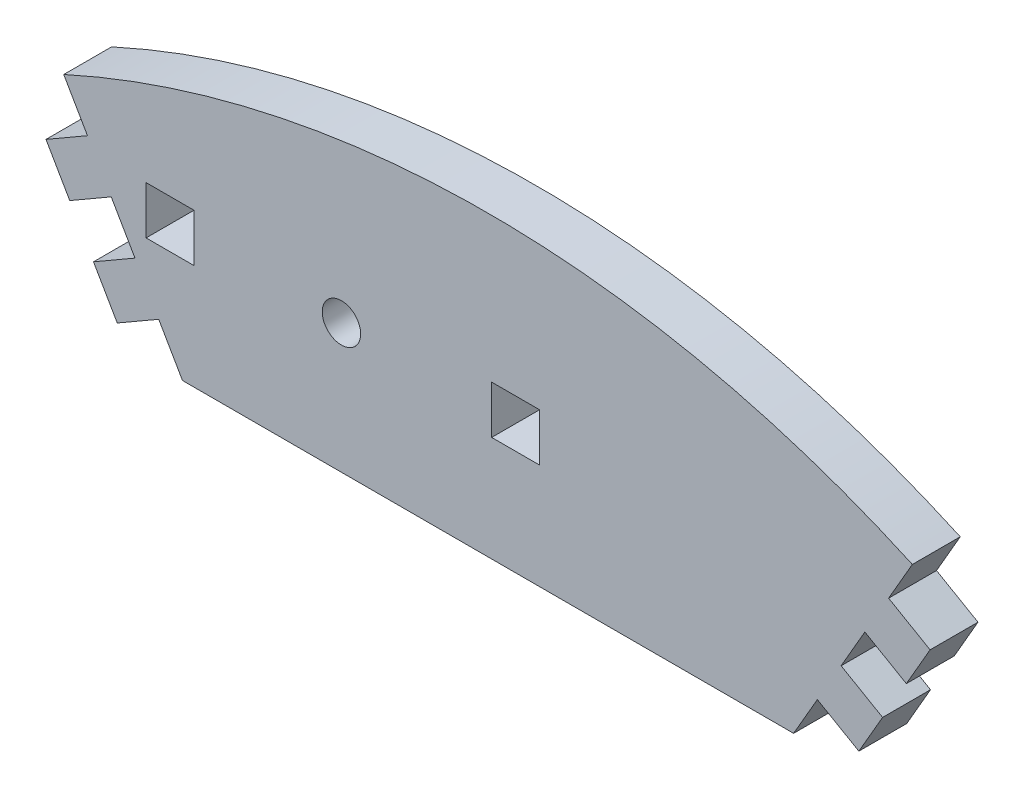
from build123d import *

# Parameters (mm, degrees)
BOSS_EXTRUDE1_DEPTH = 5.15
SKETCH2_R           = 2.0675
SKETCH2_W           = 5.15
SKETCH2_H           = 5.15
CUT_EXTRUDE1_DEPTH  = 6.15


with BuildPart() as part:
    # Sketch1 → Boss-Extrude1 (new body)
    with BuildSketch(Plane.XY):
        with BuildLine():
            Line((-32.85, 77.986683936), (32.85, 77.986683936))
            Line((32.85, 77.986683936), (35.403, 82.408609648))
            Line((35.403, 82.408609648), (39.863030829, 79.833609648))
            Line((39.863030829, 79.833609648), (42.416030829, 84.255535359))
            Line((42.416030829, 84.255535359), (37.956, 86.830535359))
            Line((37.956, 86.830535359), (40.509, 91.252461071))
            Line((40.509, 91.252461071), (44.969030829, 88.677461071))
            Line((44.969030829, 88.677461071), (47.522030829, 93.099386783))
            Line((47.522030829, 93.099386783), (43.062, 95.674386783))
            Line((43.062, 95.674386783), (45.615, 100.096312495))
            ThreePointArc((45.615, 100.096312495), (0, 110), (-45.615, 100.096312495))
            Line((-45.615, 100.096312495), (-43.062, 95.674386783))
            Line((-43.062, 95.674386783), (-47.522030829, 93.099386783))
            Line((-47.522030829, 93.099386783), (-44.969030829, 88.677461071))
            Line((-44.969030829, 88.677461071), (-40.509, 91.252461071))
            Line((-40.509, 91.252461071), (-37.956, 86.830535359))
            Line((-37.956, 86.830535359), (-42.416030829, 84.255535359))
            Line((-42.416030829, 84.255535359), (-39.863030829, 79.833609648))
            Line((-39.863030829, 79.833609648), (-35.403, 82.408609648))
            Line((-35.403, 82.408609648), (-32.85, 77.986683936))
        make_face()
    extrude(amount=BOSS_EXTRUDE1_DEPTH)

    # Sketch2 → Cut-Extrude1 (cut, through all)
    with BuildSketch(Plane.XY.offset(5.15)):
        with Locations((-15.76, 91.897414387)):
            Circle(SKETCH2_R)
        with Locations((2.965, 91.882821113)):
            Rectangle(SKETCH2_W, SKETCH2_H)
        with Locations((-34.185, 91.882821113)):
            Rectangle(SKETCH2_W, SKETCH2_H)
    extrude(amount=-CUT_EXTRUDE1_DEPTH, mode=Mode.SUBTRACT)


solid = part.part
